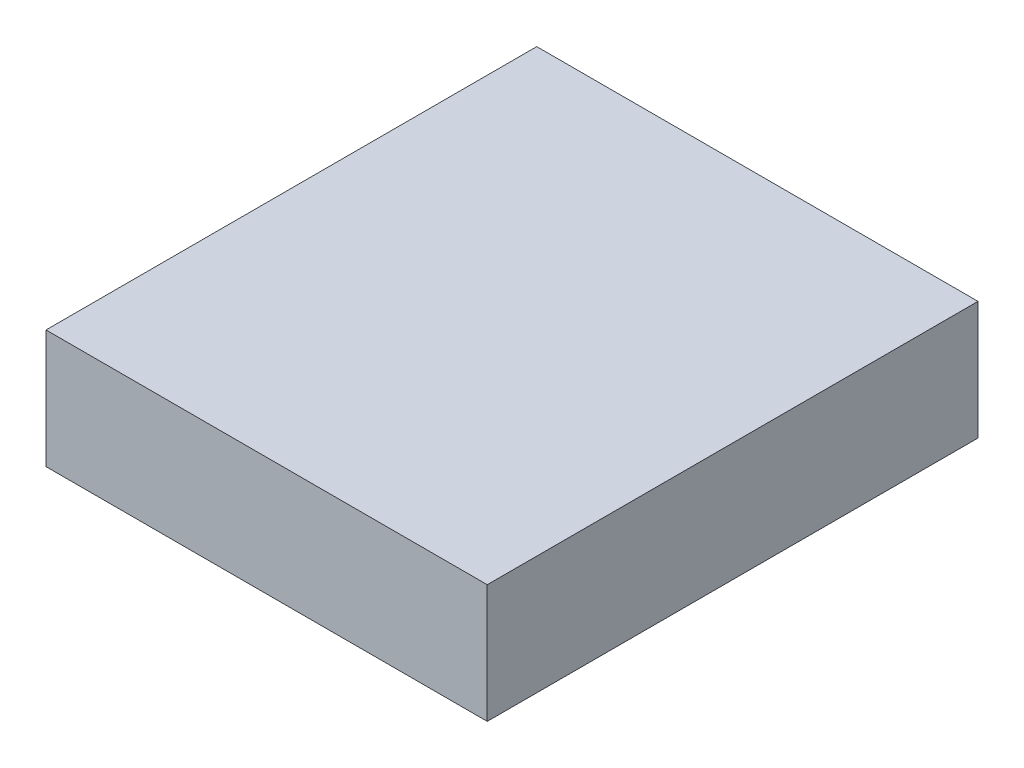
from build123d import *

# Parameters (mm, degrees)
CROQUIS1_W              = 52.07
CROQUIS1_H              = 57.912
SALIENTE_EXTRUIR1_DEPTH = 6.985


with BuildPart() as part:
    # Croquis1 → Saliente-Extruir1 (new body, symmetric)
    with BuildSketch(Plane(origin=(0, 0, 0), x_dir=(1, 0, 0), z_dir=(0, 1, 0))):
        Rectangle(CROQUIS1_W, CROQUIS1_H)
    extrude(amount=SALIENTE_EXTRUIR1_DEPTH, both=True)


solid = part.part
